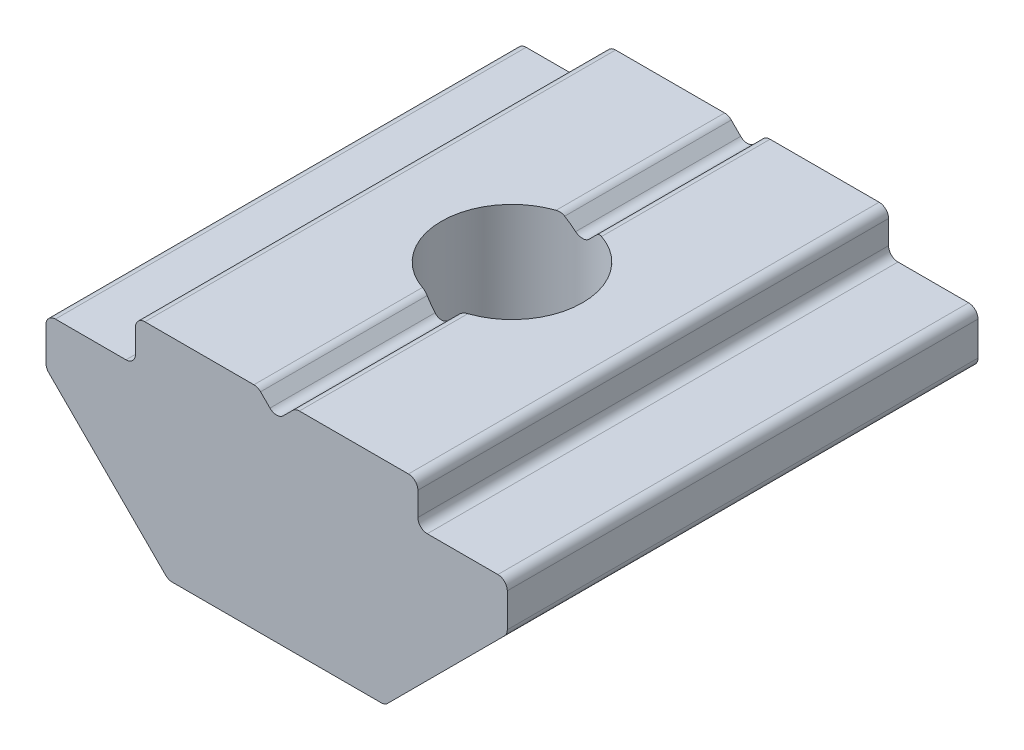
from build123d import *

# Parameters (mm, degrees)
EXTRUDE_BODY_DEPTH = 10
SKETCH2_W          = 1.9
SKETCH2_H          = 0.9
CUT_EXTRUDE1_DEPTH = 11
SKETCH3_W          = 1.9
SKETCH3_H          = 0.9
CUT_EXTRUDE2_DEPTH = 11
CUT_EXTRUDE3_DEPTH = 11
HOLE_REVOLVE_D     = 3
EDGE_FILLETS_R     = 0.2


with BuildPart() as part:
    # Sketch1 → Extrude Body (new body)
    with BuildSketch(Plane.XY.offset(5)):
        Polygon((4.9, -1), (4.9, 0.9), (-4.9, 0.9), (-4.9, -1), (-2.3, -3.6), (2.3, -3.6), align=None)
    extrude(amount=-EXTRUDE_BODY_DEPTH)

    # Sketch2 → Cut-Extrude1 (cut, through all)
    with BuildSketch(Plane(origin=(0, 0, -5), x_dir=(-1, 0, 0), z_dir=(0, 0, -1))):
        with Locations((3.95, 0.45)):
            Rectangle(SKETCH2_W, SKETCH2_H)
    extrude(amount=-CUT_EXTRUDE1_DEPTH, mode=Mode.SUBTRACT)

    # Sketch3 → Cut-Extrude2 (cut, through all)
    with BuildSketch(Plane(origin=(0, 0, -5), x_dir=(-1, 0, 0), z_dir=(0, 0, -1))):
        with Locations((-3.95, 0.45)):
            Rectangle(SKETCH3_W, SKETCH3_H)
    extrude(amount=-CUT_EXTRUDE2_DEPTH, mode=Mode.SUBTRACT)

    # Sketch4 → Cut-Extrude3 (cut, through all)
    with BuildSketch(Plane(origin=(0, 0, -5), x_dir=(-1, 0, 0), z_dir=(0, 0, -1))):
        Polygon((0.4, 0.9), (-0.4, 0.9), (0, 0.5), align=None)
    extrude(amount=-CUT_EXTRUDE3_DEPTH, mode=Mode.SUBTRACT)

    # Hole Revolve (through all)
    with Locations(Plane(origin=(0, -3.6, 0), x_dir=(-1, 0, 0), z_dir=(0, -1, 0))):
        with Locations((0, 0)):
            Hole(HOLE_REVOLVE_D / 2)

    # Edge Fillets
    edge_fillets_edges = [part.edges().sort_by_distance(p)[0] for p in [
        (4.9, 0, 0),
        (3, 0, 0),
        (-4.9, -1, 0),
        (3, 0.9, 0),
        (-3, 0, 0),
        (0.4, 0.9, -3.222841615),
        (0, 0.5, 3.25),
        (-0.4, 0.9, -3.222841615),
        (4.9, -1, 0),
        (-3, 0.9, 0),
        (0, 0.5, -3.25),
        (-0.4, 0.9, 3.222841615),
        (-4.9, 0, 0),
        (-2.3, -3.6, 0),
        (0.4, 0.9, 3.222841615),
        (2.3, -3.6, 0),
    ]]
    fillet(edge_fillets_edges, radius=EDGE_FILLETS_R)


solid = part.part
